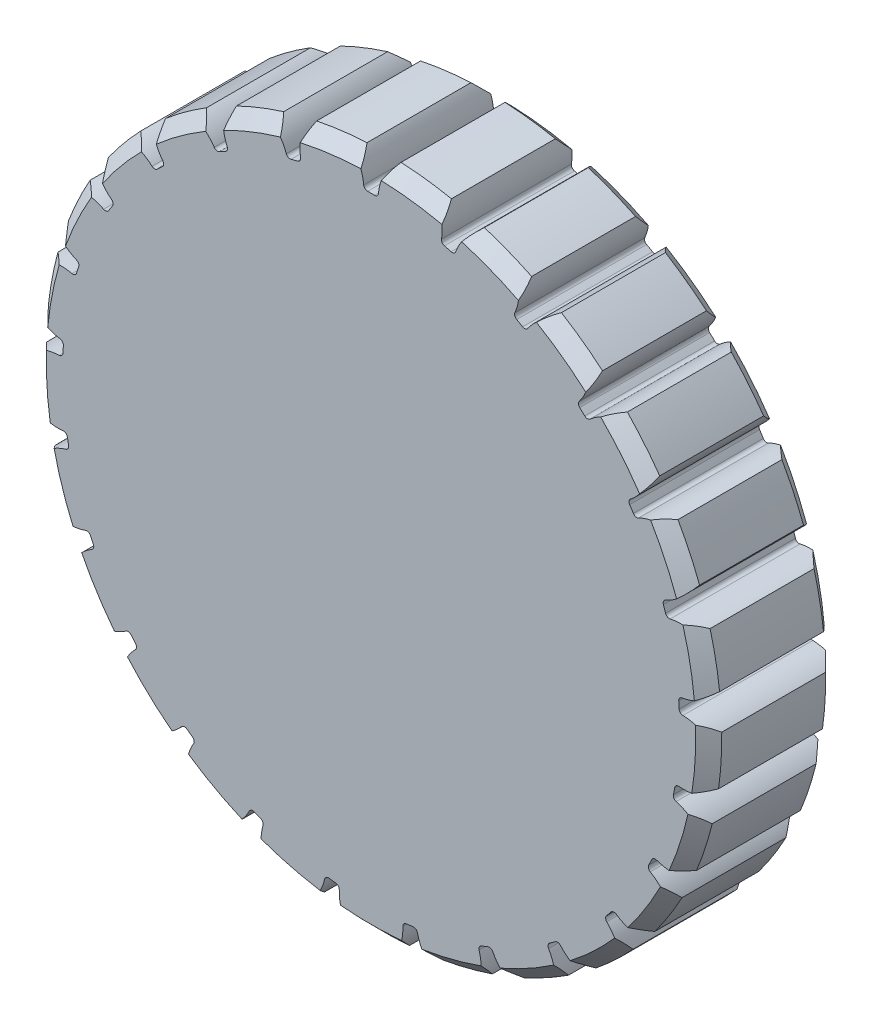
from build123d import *

# Parameters (mm, degrees)
SKETCH1_R                = 52
BOSS_EXTRUDE1_DEPTH      = 10
CUT_EXTRUDE2_DEPTH       = 20
FILLET2_R                = 0.6
CHAMFER1_SIZE            = 2
CIRPATTERN1_COUNT        = 25
FILLET2_OF_CIRPATTERN1_R = 0.6


with BuildPart() as part:
    # Sketch1 → Boss-Extrude1 (new body, symmetric)
    with BuildSketch(Plane.XY):
        Circle(SKETCH1_R)
    extrude(amount=BOSS_EXTRUDE1_DEPTH, both=True)

    # Sketch3 → Cut-Extrude2 (cut)
    with BuildSketch(Plane.XY.offset(10)):
        with BuildLine():
            ThreePointArc((-2.620075038, 51.933950425), (-1.518424295, 49.827547164), (-1.101992271, 47.487215259))
            ThreePointArc((-1.101992271, 47.487215259), (0, 47.5), (1.101992271, 47.487215259))
            ThreePointArc((1.101992271, 47.487215259), (1.518424295, 49.827547164), (2.620075038, 51.933950425))
            ThreePointArc((2.620075038, 51.933950425), (0, 52), (-2.620075038, 51.933950425))
        make_face()
    cut_extrude2 = extrude(amount=-CUT_EXTRUDE2_DEPTH, mode=Mode.SUBTRACT)

    # Fillet2
    fillet2_edges = [part.edges().sort_by_distance(p)[0] for p in [
        (-1.101992271, 47.487215259, 0),
        (1.101992271, 47.487215259, 0),
    ]]
    fillet(fillet2_edges, radius=FILLET2_R)

    # Chamfer1
    chamfer1_edges = [part.edges().sort_by_distance(p)[0] for p in [
        (-35.831244034, -37.68450545, -10),
        (-35.831244034, -37.68450545, 10),
    ]]
    chamfer(chamfer1_edges, length=CHAMFER1_SIZE)

    # CirPattern1: Cut-Extrude2 ×25 about axis
    cirpattern1_axis = Axis((0, 0, 0), (0, 0, 1))
    for i in range(1, CIRPATTERN1_COUNT):
        add(cut_extrude2.rotate(cirpattern1_axis, i * 360 / CIRPATTERN1_COUNT), mode=Mode.SUBTRACT)

    # Fillet2 of CirPattern1
    fillet2_of_cirpattern1_edges = [part.edges().sort_by_distance(p)[0] for p in [
        (-12.876961362, 45.721262735, 0),
        (-10.742219047, 46.269371402, 0),
        (-23.842823612, 41.082475123, 0),
        (-21.911457236, 42.144252773, 0),
        (-33.310553567, 33.862324508, 0),
        (-31.703917981, 35.371055747, 0),
        (-40.685258934, 24.514479507, 0),
        (-39.504304961, 26.375365203, 0),
        (-45.503559852, 13.6262996, 0),
        (-44.822491173, 15.722413461, 0),
        (-47.462704754, 1.881929176, 0),
        (-47.32431542, 4.081564658, 0),
        (-46.439593361, -9.980689779, 0),
        (-46.852578882, -7.815743863, 0),
        (-42.498511524, -21.21618529, 0),
        (-43.436922501, -19.221960453, 0),
        (-35.88709191, -31.11858985, 0),
        (-37.291964529, -29.420390574, 0),
        (-27.020754327, -39.065698965, 0),
        (-28.803815276, -37.770229355, 0),
        (-16.456603374, -44.55816654, 0),
        (-18.505816376, -43.746825716, 0),
        (-4.858423509, -47.250880637, 0),
        (-7.045028974, -46.974648128, 0),
        (7.045028974, -46.974648128, 0),
        (4.858423509, -47.250880637, 0),
        (18.505816376, -43.746825716, 0),
        (16.456603374, -44.55816654, 0),
        (28.803815276, -37.770229355, 0),
        (27.020754327, -39.065698965, 0),
        (37.291964529, -29.420390574, 0),
        (35.88709191, -31.11858985, 0),
        (43.436922501, -19.221960453, 0),
        (42.498511524, -21.21618529, 0),
        (46.852578882, -7.815743863, 0),
        (46.439593361, -9.980689779, 0),
        (47.32431542, 4.081564658, 0),
        (47.462704754, 1.881929176, 0),
        (44.822491173, 15.722413461, 0),
        (45.503559852, 13.6262996, 0),
        (39.504304961, 26.375365203, 0),
        (40.685258934, 24.514479507, 0),
        (31.703917981, 35.371055747, 0),
        (33.310553567, 33.862324508, 0),
        (21.911457236, 42.144252773, 0),
        (23.842823612, 41.082475123, 0),
        (10.742219047, 46.269371402, 0),
        (12.876961362, 45.721262735, 0),
    ]]
    fillet(fillet2_of_cirpattern1_edges, radius=FILLET2_OF_CIRPATTERN1_R)


solid = part.part
